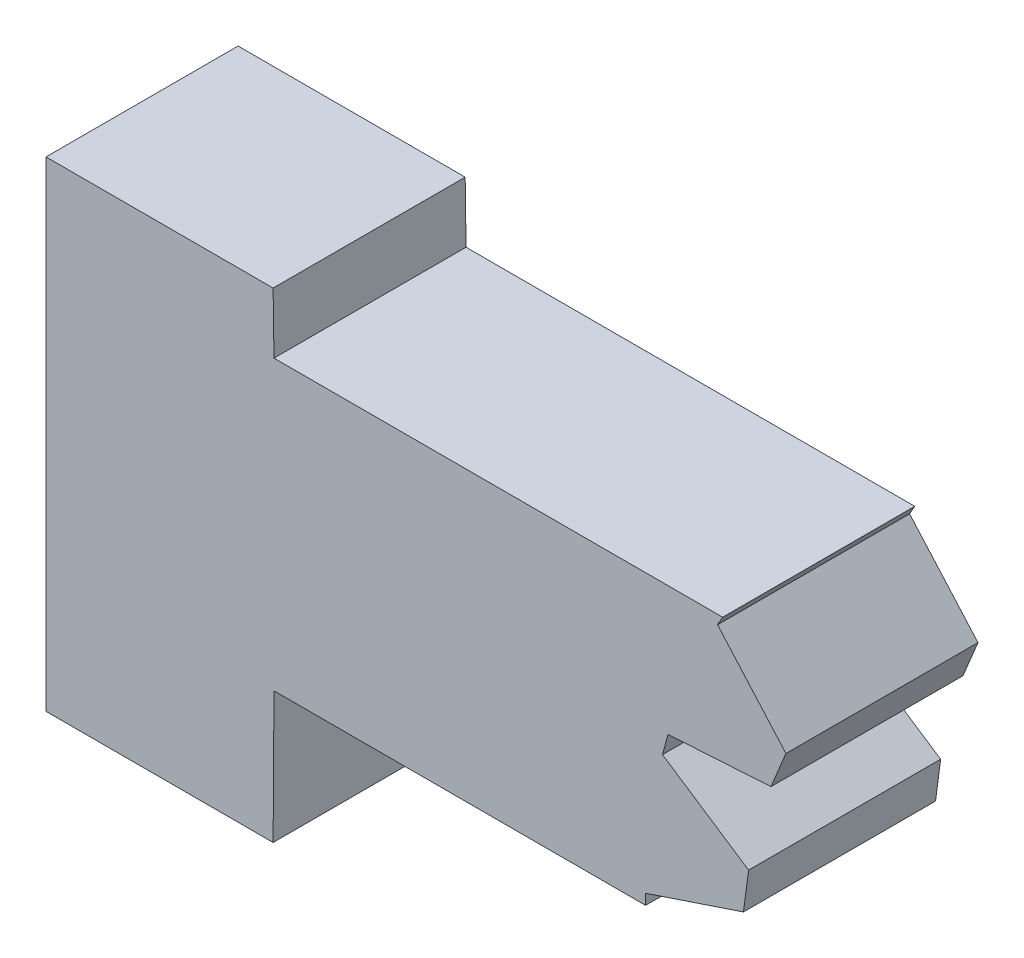
from build123d import *

# Parameters (mm, degrees)
BOSS_EXTRUDE1_DEPTH = 4


with BuildPart() as part:
    # Sketch1 → Boss-Extrude1 (new body)
    with BuildSketch(Plane.XY):
        Polygon((4.747783705, 2.744764558), (12.487074911, 2.744764558), (12.487074911, 2.962852563), (14.525675328, 3.644764558), (14.632097115, 4.453118281), (12.839452134, 5.639423302), (12.952342793, 6.060736975), (15.097971396, 6.191784769), (15.409984287, 6.945050522), (13.985460535, 8.554903841), (14.092783705, 8.744756719), (4.747783705, 8.744756719), (4.73, 10), (0, 10), (0, 0), (4.73, 0), align=None)
    extrude(amount=BOSS_EXTRUDE1_DEPTH)


solid = part.part
